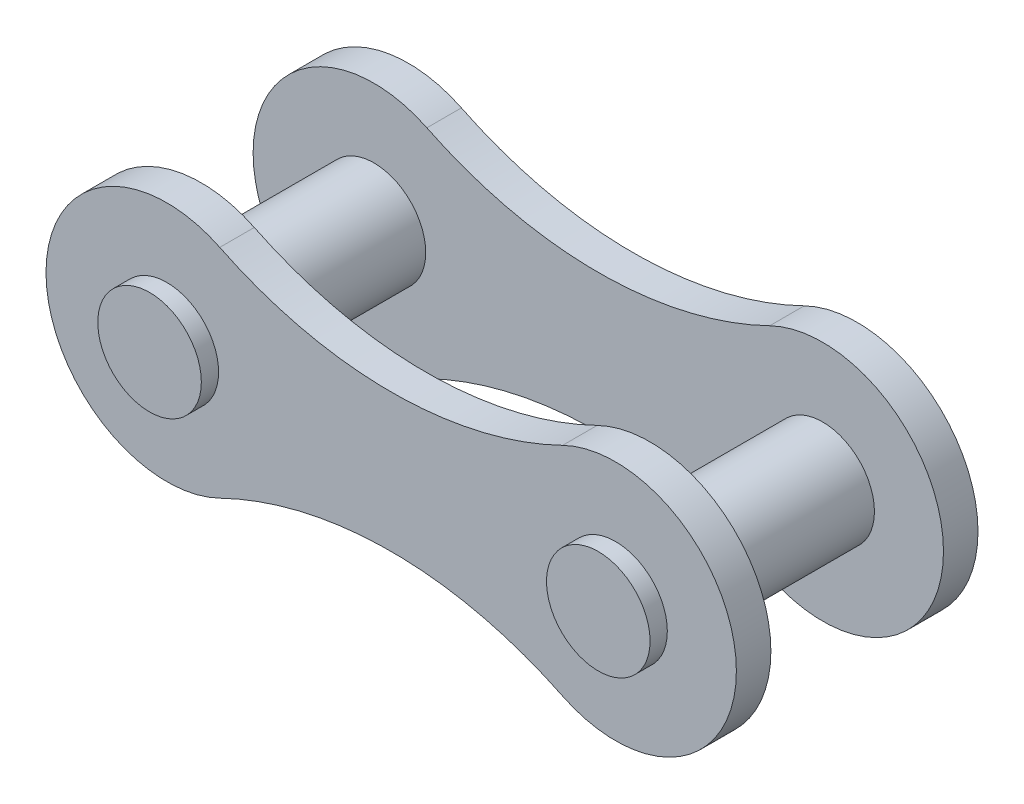
from build123d import *

# Parameters (mm, degrees)
CROQUIS1_R                = 1.5
SALIENTE_EXTRUIR1_DEPTH   = 1
CROQUIS2_R                = 1.5
SALIENTE_EXTRUIR2_DEPTH   = 5
SALIENTE_EXTRUIR2_2_DEPTH = 5
CROQUIS3_R                = 1.5
SALIENTE_EXTRUIR4_DEPTH   = 1
CROQUIS4_R                = 1.5
SALIENTE_EXTRUIR5_DEPTH   = 1.5
CROQUIS5_R                = 1.5
SALIENTE_EXTRUIR6_DEPTH   = 1.5


with BuildPart() as part:
    # Croquis1 → Saliente-Extruir1 (new body)
    with BuildSketch(Plane.XY):
        with BuildLine():
            ThreePointArc((4.966292135, -3.146067416), (10, 0), (4.966292135, 3.146067416))
            ThreePointArc((4.966292135, 3.146067416), (0, 2), (-4.966292135, 3.146067416))
            ThreePointArc((-4.966292135, 3.146067416), (-10, 0), (-4.966292135, -3.146067416))
            ThreePointArc((-4.966292135, -3.146067416), (0, -2), (4.966292135, -3.146067416))
        make_face()
        with Locations((6.5, 0)):
            Circle(CROQUIS1_R, mode=Mode.SUBTRACT)
        with Locations((-6.5, 0)):
            Circle(CROQUIS1_R, mode=Mode.SUBTRACT)
    extrude(amount=SALIENTE_EXTRUIR1_DEPTH)



with BuildPart() as body_2:
    # Croquis2 → Saliente-Extruir2 (new body)
    with BuildSketch(Plane.XY.offset(1)):
        with Locations((-6.5, 0)):
            Circle(CROQUIS2_R)
    extrude(amount=SALIENTE_EXTRUIR2_DEPTH)



with BuildPart() as body_3:
    # Croquis2 → Saliente-Extruir2 2 (new body)
    with BuildSketch(Plane.XY.offset(1)):
        with Locations((6.5, 0)):
            Circle(CROQUIS2_R)
    extrude(amount=SALIENTE_EXTRUIR2_2_DEPTH)


with BuildPart() as body_4:
    # Croquis3 → Saliente-Extruir4 (new body)
    with BuildSketch(Plane.XY.offset(6)):
        with BuildLine():
            ThreePointArc((-4.966292135, 3.146067416), (0, 2), (4.966292135, 3.146067416))
            ThreePointArc((4.966292135, 3.146067416), (10, 0), (4.966292135, -3.146067416))
            ThreePointArc((4.966292135, -3.146067416), (0, -2), (-4.966292135, -3.146067416))
            ThreePointArc((-4.966292135, -3.146067416), (-10, 0), (-4.966292135, 3.146067416))
        make_face()
        with Locations((-6.5, 0)):
            Circle(CROQUIS3_R, mode=Mode.SUBTRACT)
        with Locations((6.5, 0)):
            Circle(CROQUIS3_R, mode=Mode.SUBTRACT)
    extrude(amount=SALIENTE_EXTRUIR4_DEPTH)


with BuildPart() as body_2_1:
    add(body_2.part)

    add(body_3.part)  # Saliente-Extruir5 merges body 3

    add(body_4.part)  # Saliente-Extruir5 merges body 4
    # Croquis4 → Saliente-Extruir5 (add)
    with BuildSketch(Plane.XY.offset(6)):
        with Locations((-6.5, 0)):
            Circle(CROQUIS4_R)
        with Locations((6.5, 0)):
            Circle(CROQUIS4_R)
    extrude(amount=SALIENTE_EXTRUIR5_DEPTH)


with BuildPart() as part_1:
    add(part.part)

    add(body_2_1.part)  # Saliente-Extruir6 merges body 2
    # Croquis5 → Saliente-Extruir6 (add)
    with BuildSketch(Plane(origin=(0, 0, 1), x_dir=(-1, 0, 0), z_dir=(0, 0, -1))):
        with Locations((-6.5, 0)):
            Circle(CROQUIS5_R)
        with Locations((6.5, 0)):
            Circle(CROQUIS5_R)
    extrude(amount=SALIENTE_EXTRUIR6_DEPTH)


solid = part_1.part
